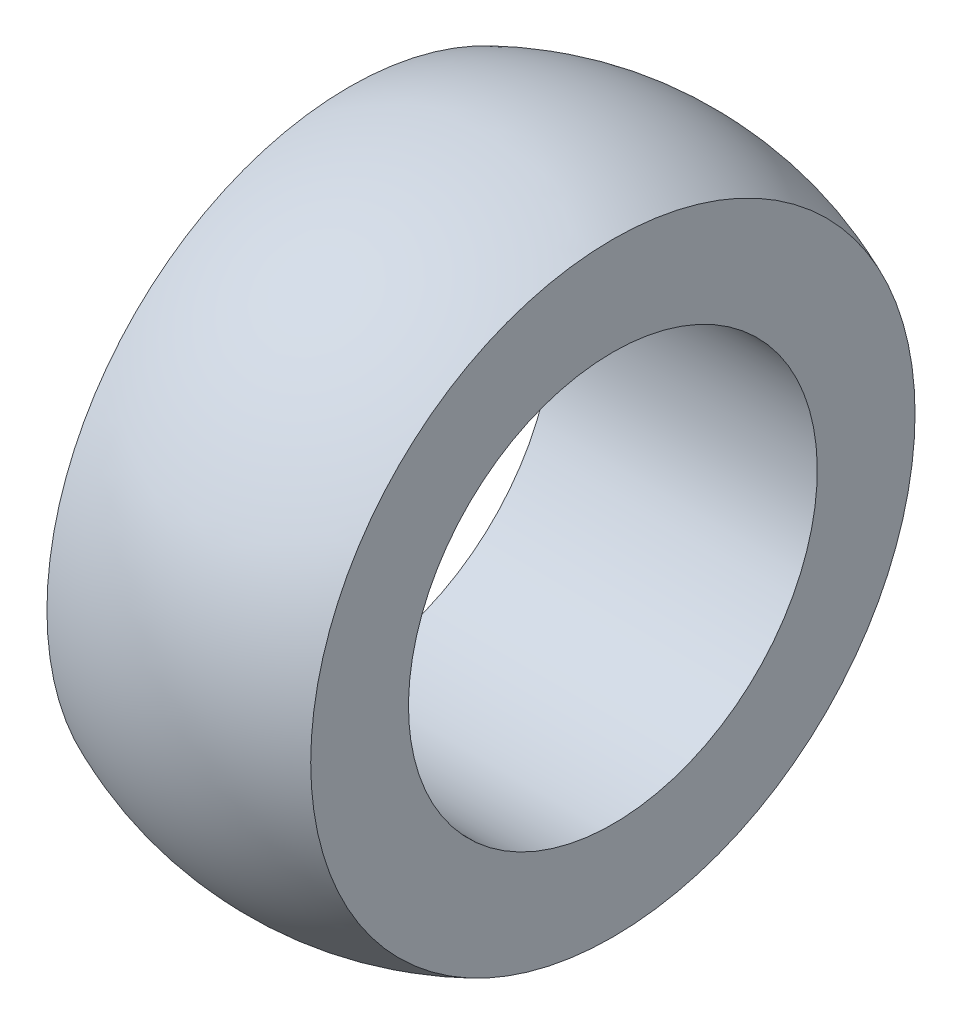
from build123d import *


with BuildPart() as part:
    # Sketch1 → Revolve1 (revolve)
    with BuildSketch(Plane.XY):
        with BuildLine():
            Line((-2.54, 3.937), (-2.54, 5.819871133))
            ThreePointArc((-2.54, 5.819871133), (0, 6.35), (2.54, 5.819871133))
            Line((2.54, 5.819871133), (2.54, 3.937))
            Line((2.54, 3.937), (-2.54, 3.937))
        make_face()
    revolve(axis=Axis((11.385897249, 0, 0), (-1, 0, 0)))


solid = part.part
